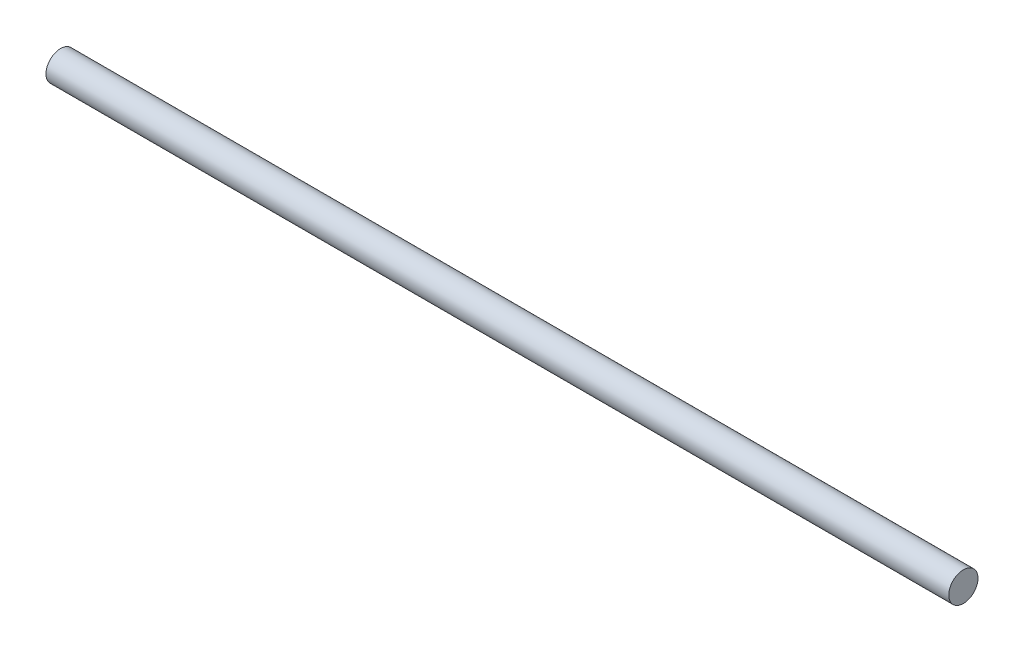
from build123d import *

# Parameters (mm, degrees)
SKICA1_R                = 1.15
P_IDAT_VYSUNUT_M1_DEPTH = 71


with BuildPart() as part:
    # Skica1 → Přidat vysunutím1 (new body)
    with BuildSketch(Plane(origin=(0, 0, 0), x_dir=(0, 0, -1), z_dir=(1, 0, 0))):
        Circle(SKICA1_R)
    extrude(amount=P_IDAT_VYSUNUT_M1_DEPTH)


solid = part.part
